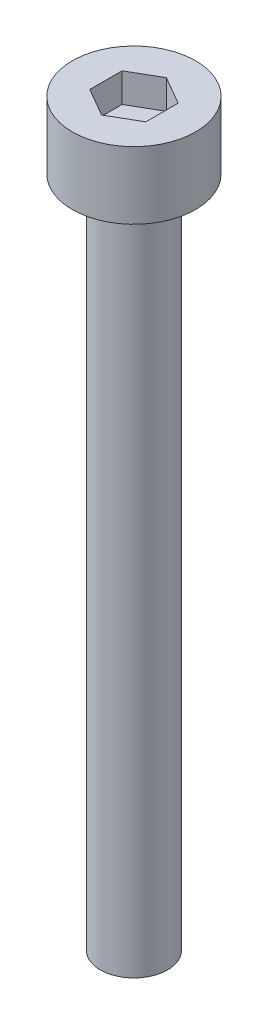
from build123d import *

# Parameters (mm, degrees)
SKETCH1_R           = 2.75
BOSS_EXTRUDE1_DEPTH = 3
CUT_EXTRUDE1_DEPTH  = 1.3
SKETCH3_R           = 1.5
BOSS_EXTRUDE2_DEPTH = 30


with BuildPart() as part:
    # Sketch1 → Boss-Extrude1 (new body)
    with BuildSketch(Plane(origin=(0, 0, 0), x_dir=(1, 0, 0), z_dir=(0, 1, 0))):
        Circle(SKETCH1_R)
    extrude(amount=BOSS_EXTRUDE1_DEPTH)

    # Sketch2 → Cut-Extrude1 (cut)
    with BuildSketch(Plane(origin=(0, 3, 0), x_dir=(1, 0, 0), z_dir=(0, 1, 0))):
        Polygon((0, 1.443375673), (-1.25, 0.721687836), (-1.25, -0.721687836), (0, -1.443375673), (1.25, -0.721687836), (1.25, 0.721687836), align=None)
    extrude(amount=-CUT_EXTRUDE1_DEPTH, mode=Mode.SUBTRACT)

    # Sketch3 → Boss-Extrude2 (add)
    with BuildSketch(Plane.XZ):
        Circle(SKETCH3_R)
    extrude(amount=BOSS_EXTRUDE2_DEPTH)


solid = part.part
